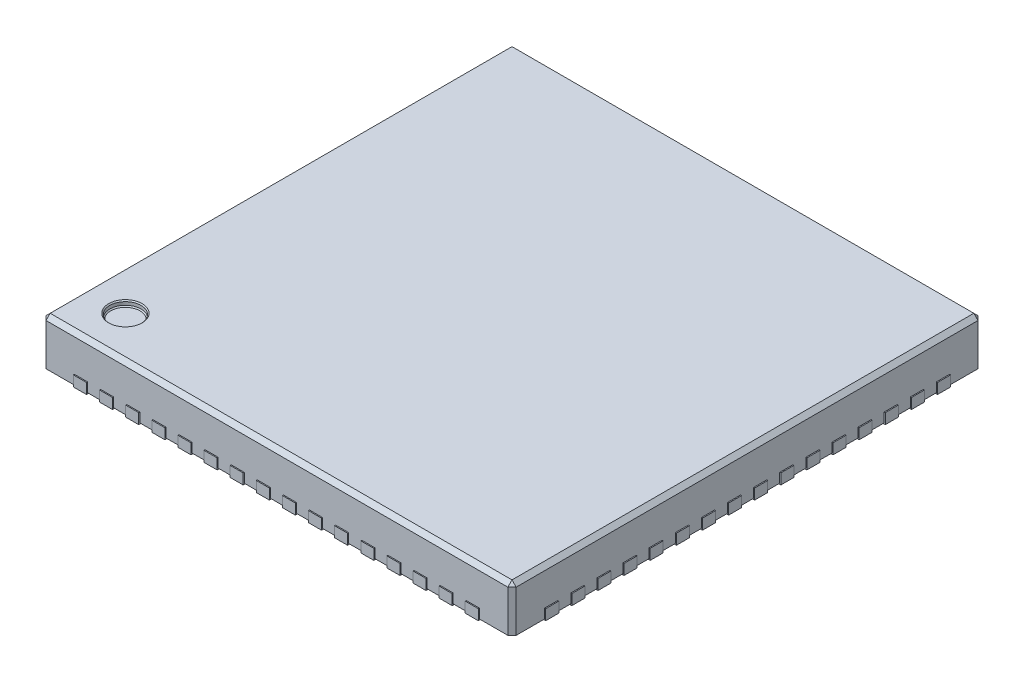
from build123d import *

# Parameters (mm, degrees)
BOSS_EXTRUDE1_DEPTH = 0.88
CHAMFER1_SIZE       = 0.08
SKETCH2_R           = 0.3
CUT_EXTRUDE1_DEPTH  = 0.1
CHAMFER2_SIZE       = 0.02
BOSS_EXTRUDE2_DEPTH = 0.2
LPATTERN1_COUNT     = 8
LPATTERN1_PITCH     = 0.5
LPATTERN2_COUNT     = 9
LPATTERN2_PITCH     = 0.5
CIRPATTERN2_COUNT   = 4
BOSS_EXTRUDE3_DEPTH = 0.2


with BuildPart() as part:
    # 3DSketch1 → Boss-Extrude1 (new body)
    with BuildSketch(Plane(origin=(-4.5, 0.02, 4.5), x_dir=(0.7071067811865474, 0, -0.7071067811865477), z_dir=(0, 1, 0))):
        Polygon((0, 0), (6.363961031, -6.363961031), (12.727922061, 0), (6.363961031, 6.363961031), align=None)
    extrude(amount=BOSS_EXTRUDE1_DEPTH)

    # Chamfer1
    chamfer1_edges = [part.edges().sort_by_distance(p)[0] for p in [
        (-4.5, 0.9, 0),
        (-4.5, 0.46, -4.5),
        (0, 0.9, -4.5),
        (4.5, 0.46, -4.5),
        (4.5, 0.9, 0),
        (-4.5, 0.46, 4.5),
        (0, 0.9, 4.5),
        (4.5, 0.46, 4.5),
    ]]
    chamfer(chamfer1_edges, length=CHAMFER1_SIZE)

    # Sketch2 → Cut-Extrude1 (cut)
    with BuildSketch(Plane(origin=(0, 0.9, 0), x_dir=(1, 0, 0), z_dir=(0, 1, 0))):
        with Locations(Location((-3.7, -3.7, 0), (0, 0, 270))):
            Circle(SKETCH2_R)
    extrude(amount=-CUT_EXTRUDE1_DEPTH, mode=Mode.SUBTRACT)

    # Chamfer2
    chamfer2_edges = [part.edges().sort_by_distance(p)[0] for p in [
        (-3.7, 0.8, 3.4),
        (-3.7, 0.9, 3.4),
    ]]
    chamfer(chamfer2_edges, length=CHAMFER2_SIZE)


with BuildPart() as body_2:
    # Sketch3 → Boss-Extrude2 (new body)
    with BuildSketch(Plane(origin=(0, 0, 0), x_dir=(1, 0, 0), z_dir=(0, 1, 0))):
        with BuildLine():
            Line((0.375, 4.52), (0.125, 4.52))
            Line((0.125, 4.52), (0.125, 4.225))
            ThreePointArc((0.125, 4.225), (0.25, 4.1), (0.375, 4.225))
            Line((0.375, 4.225), (0.375, 4.52))
        make_face()
    extrude(amount=BOSS_EXTRUDE2_DEPTH)


with BuildPart() as lpattern1_1:
    # LPattern1: pattern copy
    add(body_2.part.moved(Location(Vector(1, 0, 0) * (1 * LPATTERN1_PITCH))))


with BuildPart() as lpattern1_2:
    # LPattern1: pattern copy
    add(body_2.part.moved(Location(Vector(1, 0, 0) * (2 * LPATTERN1_PITCH))))


with BuildPart() as lpattern1_3:
    # LPattern1: pattern copy
    add(body_2.part.moved(Location(Vector(1, 0, 0) * (3 * LPATTERN1_PITCH))))


with BuildPart() as lpattern1_4:
    # LPattern1: pattern copy
    add(body_2.part.moved(Location(Vector(1, 0, 0) * (4 * LPATTERN1_PITCH))))


with BuildPart() as lpattern1_5:
    # LPattern1: pattern copy
    add(body_2.part.moved(Location(Vector(1, 0, 0) * (5 * LPATTERN1_PITCH))))


with BuildPart() as lpattern1_6:
    # LPattern1: pattern copy
    add(body_2.part.moved(Location(Vector(1, 0, 0) * (6 * LPATTERN1_PITCH))))


with BuildPart() as lpattern1_7:
    # LPattern1: pattern copy
    add(body_2.part.moved(Location(Vector(1, 0, 0) * (7 * LPATTERN1_PITCH))))


with BuildPart() as lpattern2_1:
    # LPattern2: pattern copy
    add(body_2.part.moved(Location(Vector(-1, 0, 0) * (1 * LPATTERN2_PITCH))))


with BuildPart() as lpattern2_2:
    # LPattern2: pattern copy
    add(body_2.part.moved(Location(Vector(-1, 0, 0) * (2 * LPATTERN2_PITCH))))


with BuildPart() as lpattern2_3:
    # LPattern2: pattern copy
    add(body_2.part.moved(Location(Vector(-1, 0, 0) * (3 * LPATTERN2_PITCH))))


with BuildPart() as lpattern2_4:
    # LPattern2: pattern copy
    add(body_2.part.moved(Location(Vector(-1, 0, 0) * (4 * LPATTERN2_PITCH))))


with BuildPart() as lpattern2_5:
    # LPattern2: pattern copy
    add(body_2.part.moved(Location(Vector(-1, 0, 0) * (5 * LPATTERN2_PITCH))))


with BuildPart() as lpattern2_6:
    # LPattern2: pattern copy
    add(body_2.part.moved(Location(Vector(-1, 0, 0) * (6 * LPATTERN2_PITCH))))


with BuildPart() as lpattern2_7:
    # LPattern2: pattern copy
    add(body_2.part.moved(Location(Vector(-1, 0, 0) * (7 * LPATTERN2_PITCH))))


with BuildPart() as lpattern2_8:
    # LPattern2: pattern copy
    add(body_2.part.moved(Location(Vector(-1, 0, 0) * (8 * LPATTERN2_PITCH))))


with BuildPart() as cirpattern2_1:
    # CirPattern2: pattern copy
    add(lpattern1_7.part.rotate(Axis((0, 0, 0), (0, 1, 0)), 1 * 360 / CIRPATTERN2_COUNT))


with BuildPart() as cirpattern2_2:
    # CirPattern2: pattern copy
    add(lpattern1_7.part.rotate(Axis((0, 0, 0), (0, 1, 0)), 2 * 360 / CIRPATTERN2_COUNT))


with BuildPart() as cirpattern2_3:
    # CirPattern2: pattern copy
    add(lpattern1_7.part.rotate(Axis((0, 0, 0), (0, 1, 0)), 3 * 360 / CIRPATTERN2_COUNT))


with BuildPart() as cirpattern2_4:
    # CirPattern2: pattern copy
    add(lpattern1_6.part.rotate(Axis((0, 0, 0), (0, 1, 0)), 1 * 360 / CIRPATTERN2_COUNT))


with BuildPart() as cirpattern2_5:
    # CirPattern2: pattern copy
    add(lpattern1_6.part.rotate(Axis((0, 0, 0), (0, 1, 0)), 2 * 360 / CIRPATTERN2_COUNT))


with BuildPart() as cirpattern2_6:
    # CirPattern2: pattern copy
    add(lpattern1_6.part.rotate(Axis((0, 0, 0), (0, 1, 0)), 3 * 360 / CIRPATTERN2_COUNT))


with BuildPart() as cirpattern2_7:
    # CirPattern2: pattern copy
    add(lpattern1_5.part.rotate(Axis((0, 0, 0), (0, 1, 0)), 1 * 360 / CIRPATTERN2_COUNT))


with BuildPart() as cirpattern2_8:
    # CirPattern2: pattern copy
    add(lpattern1_5.part.rotate(Axis((0, 0, 0), (0, 1, 0)), 2 * 360 / CIRPATTERN2_COUNT))


with BuildPart() as cirpattern2_9:
    # CirPattern2: pattern copy
    add(lpattern1_5.part.rotate(Axis((0, 0, 0), (0, 1, 0)), 3 * 360 / CIRPATTERN2_COUNT))


with BuildPart() as cirpattern2_10:
    # CirPattern2: pattern copy
    add(lpattern1_4.part.rotate(Axis((0, 0, 0), (0, 1, 0)), 1 * 360 / CIRPATTERN2_COUNT))


with BuildPart() as cirpattern2_11:
    # CirPattern2: pattern copy
    add(lpattern1_4.part.rotate(Axis((0, 0, 0), (0, 1, 0)), 2 * 360 / CIRPATTERN2_COUNT))


with BuildPart() as cirpattern2_12:
    # CirPattern2: pattern copy
    add(lpattern1_4.part.rotate(Axis((0, 0, 0), (0, 1, 0)), 3 * 360 / CIRPATTERN2_COUNT))


with BuildPart() as cirpattern2_13:
    # CirPattern2: pattern copy
    add(lpattern1_3.part.rotate(Axis((0, 0, 0), (0, 1, 0)), 1 * 360 / CIRPATTERN2_COUNT))


with BuildPart() as cirpattern2_14:
    # CirPattern2: pattern copy
    add(lpattern1_3.part.rotate(Axis((0, 0, 0), (0, 1, 0)), 2 * 360 / CIRPATTERN2_COUNT))


with BuildPart() as cirpattern2_15:
    # CirPattern2: pattern copy
    add(lpattern1_3.part.rotate(Axis((0, 0, 0), (0, 1, 0)), 3 * 360 / CIRPATTERN2_COUNT))


with BuildPart() as cirpattern2_16:
    # CirPattern2: pattern copy
    add(lpattern1_2.part.rotate(Axis((0, 0, 0), (0, 1, 0)), 1 * 360 / CIRPATTERN2_COUNT))


with BuildPart() as cirpattern2_17:
    # CirPattern2: pattern copy
    add(lpattern1_2.part.rotate(Axis((0, 0, 0), (0, 1, 0)), 2 * 360 / CIRPATTERN2_COUNT))


with BuildPart() as cirpattern2_18:
    # CirPattern2: pattern copy
    add(lpattern1_2.part.rotate(Axis((0, 0, 0), (0, 1, 0)), 3 * 360 / CIRPATTERN2_COUNT))


with BuildPart() as cirpattern2_19:
    # CirPattern2: pattern copy
    add(lpattern1_1.part.rotate(Axis((0, 0, 0), (0, 1, 0)), 1 * 360 / CIRPATTERN2_COUNT))


with BuildPart() as cirpattern2_20:
    # CirPattern2: pattern copy
    add(lpattern1_1.part.rotate(Axis((0, 0, 0), (0, 1, 0)), 2 * 360 / CIRPATTERN2_COUNT))


with BuildPart() as cirpattern2_21:
    # CirPattern2: pattern copy
    add(lpattern1_1.part.rotate(Axis((0, 0, 0), (0, 1, 0)), 3 * 360 / CIRPATTERN2_COUNT))


with BuildPart() as cirpattern2_22:
    # CirPattern2: pattern copy
    add(body_2.part.rotate(Axis((0, 0, 0), (0, 1, 0)), 1 * 360 / CIRPATTERN2_COUNT))


with BuildPart() as cirpattern2_23:
    # CirPattern2: pattern copy
    add(body_2.part.rotate(Axis((0, 0, 0), (0, 1, 0)), 2 * 360 / CIRPATTERN2_COUNT))


with BuildPart() as cirpattern2_24:
    # CirPattern2: pattern copy
    add(body_2.part.rotate(Axis((0, 0, 0), (0, 1, 0)), 3 * 360 / CIRPATTERN2_COUNT))


with BuildPart() as cirpattern2_25:
    # CirPattern2: pattern copy
    add(lpattern2_1.part.rotate(Axis((0, 0, 0), (0, 1, 0)), 1 * 360 / CIRPATTERN2_COUNT))


with BuildPart() as cirpattern2_26:
    # CirPattern2: pattern copy
    add(lpattern2_1.part.rotate(Axis((0, 0, 0), (0, 1, 0)), 2 * 360 / CIRPATTERN2_COUNT))


with BuildPart() as cirpattern2_27:
    # CirPattern2: pattern copy
    add(lpattern2_1.part.rotate(Axis((0, 0, 0), (0, 1, 0)), 3 * 360 / CIRPATTERN2_COUNT))


with BuildPart() as cirpattern2_28:
    # CirPattern2: pattern copy
    add(lpattern2_2.part.rotate(Axis((0, 0, 0), (0, 1, 0)), 1 * 360 / CIRPATTERN2_COUNT))


with BuildPart() as cirpattern2_29:
    # CirPattern2: pattern copy
    add(lpattern2_2.part.rotate(Axis((0, 0, 0), (0, 1, 0)), 2 * 360 / CIRPATTERN2_COUNT))


with BuildPart() as cirpattern2_30:
    # CirPattern2: pattern copy
    add(lpattern2_2.part.rotate(Axis((0, 0, 0), (0, 1, 0)), 3 * 360 / CIRPATTERN2_COUNT))


with BuildPart() as cirpattern2_31:
    # CirPattern2: pattern copy
    add(lpattern2_3.part.rotate(Axis((0, 0, 0), (0, 1, 0)), 1 * 360 / CIRPATTERN2_COUNT))


with BuildPart() as cirpattern2_32:
    # CirPattern2: pattern copy
    add(lpattern2_3.part.rotate(Axis((0, 0, 0), (0, 1, 0)), 2 * 360 / CIRPATTERN2_COUNT))


with BuildPart() as cirpattern2_33:
    # CirPattern2: pattern copy
    add(lpattern2_3.part.rotate(Axis((0, 0, 0), (0, 1, 0)), 3 * 360 / CIRPATTERN2_COUNT))


with BuildPart() as cirpattern2_34:
    # CirPattern2: pattern copy
    add(lpattern2_4.part.rotate(Axis((0, 0, 0), (0, 1, 0)), 1 * 360 / CIRPATTERN2_COUNT))


with BuildPart() as cirpattern2_35:
    # CirPattern2: pattern copy
    add(lpattern2_4.part.rotate(Axis((0, 0, 0), (0, 1, 0)), 2 * 360 / CIRPATTERN2_COUNT))


with BuildPart() as cirpattern2_36:
    # CirPattern2: pattern copy
    add(lpattern2_4.part.rotate(Axis((0, 0, 0), (0, 1, 0)), 3 * 360 / CIRPATTERN2_COUNT))


with BuildPart() as cirpattern2_37:
    # CirPattern2: pattern copy
    add(lpattern2_5.part.rotate(Axis((0, 0, 0), (0, 1, 0)), 1 * 360 / CIRPATTERN2_COUNT))


with BuildPart() as cirpattern2_38:
    # CirPattern2: pattern copy
    add(lpattern2_5.part.rotate(Axis((0, 0, 0), (0, 1, 0)), 2 * 360 / CIRPATTERN2_COUNT))


with BuildPart() as cirpattern2_39:
    # CirPattern2: pattern copy
    add(lpattern2_5.part.rotate(Axis((0, 0, 0), (0, 1, 0)), 3 * 360 / CIRPATTERN2_COUNT))


with BuildPart() as cirpattern2_40:
    # CirPattern2: pattern copy
    add(lpattern2_6.part.rotate(Axis((0, 0, 0), (0, 1, 0)), 1 * 360 / CIRPATTERN2_COUNT))


with BuildPart() as cirpattern2_41:
    # CirPattern2: pattern copy
    add(lpattern2_6.part.rotate(Axis((0, 0, 0), (0, 1, 0)), 2 * 360 / CIRPATTERN2_COUNT))


with BuildPart() as cirpattern2_42:
    # CirPattern2: pattern copy
    add(lpattern2_6.part.rotate(Axis((0, 0, 0), (0, 1, 0)), 3 * 360 / CIRPATTERN2_COUNT))


with BuildPart() as cirpattern2_43:
    # CirPattern2: pattern copy
    add(lpattern2_7.part.rotate(Axis((0, 0, 0), (0, 1, 0)), 1 * 360 / CIRPATTERN2_COUNT))


with BuildPart() as cirpattern2_44:
    # CirPattern2: pattern copy
    add(lpattern2_7.part.rotate(Axis((0, 0, 0), (0, 1, 0)), 2 * 360 / CIRPATTERN2_COUNT))


with BuildPart() as cirpattern2_45:
    # CirPattern2: pattern copy
    add(lpattern2_7.part.rotate(Axis((0, 0, 0), (0, 1, 0)), 3 * 360 / CIRPATTERN2_COUNT))


with BuildPart() as cirpattern2_46:
    # CirPattern2: pattern copy
    add(lpattern2_8.part.rotate(Axis((0, 0, 0), (0, 1, 0)), 1 * 360 / CIRPATTERN2_COUNT))


with BuildPart() as cirpattern2_47:
    # CirPattern2: pattern copy
    add(lpattern2_8.part.rotate(Axis((0, 0, 0), (0, 1, 0)), 2 * 360 / CIRPATTERN2_COUNT))


with BuildPart() as cirpattern2_48:
    # CirPattern2: pattern copy
    add(lpattern2_8.part.rotate(Axis((0, 0, 0), (0, 1, 0)), 3 * 360 / CIRPATTERN2_COUNT))


with BuildPart() as body_66:
    # Sketch4 → Boss-Extrude3 (new body)
    with BuildSketch(Plane(origin=(0, 0, 0), x_dir=(1, 0, 0), z_dir=(0, 1, 0))):
        with BuildLine():
            Line((-3.178047264, -3.55), (3.45, -3.55))
            ThreePointArc((3.45, -3.55), (3.520710678, -3.520710678), (3.55, -3.45))
            Line((3.55, -3.45), (3.55, 3.45))
            ThreePointArc((3.55, 3.45), (3.520710678, 3.520710678), (3.45, 3.55))
            Line((3.45, 3.55), (-3.45, 3.55))
            ThreePointArc((-3.45, 3.55), (-3.520710678, 3.520710678), (-3.55, 3.45))
            Line((-3.55, 3.45), (-3.55, -3.178047264))
            ThreePointArc((-3.55, -3.178047264), (-3.544516836, -3.191804497), (-3.531073854, -3.198018414))
            ThreePointArc((-3.531073854, -3.198018414), (-3.300751895, -3.300751895), (-3.198018414, -3.531073854))
            ThreePointArc((-3.198018414, -3.531073854), (-3.191804497, -3.544516836), (-3.178047264, -3.55))
        make_face()
    extrude(amount=BOSS_EXTRUDE3_DEPTH)


solid = Compound([part.part, body_2.part, lpattern1_1.part, lpattern1_2.part, lpattern1_3.part, lpattern1_4.part, lpattern1_5.part, lpattern1_6.part, lpattern1_7.part, lpattern2_1.part, lpattern2_2.part, lpattern2_3.part, lpattern2_4.part, lpattern2_5.part, lpattern2_6.part, lpattern2_7.part, lpattern2_8.part, cirpattern2_1.part, cirpattern2_2.part, cirpattern2_3.part, cirpattern2_4.part, cirpattern2_5.part, cirpattern2_6.part, cirpattern2_7.part, cirpattern2_8.part, cirpattern2_9.part, cirpattern2_10.part, cirpattern2_11.part, cirpattern2_12.part, cirpattern2_13.part, cirpattern2_14.part, cirpattern2_15.part, cirpattern2_16.part, cirpattern2_17.part, cirpattern2_18.part, cirpattern2_19.part, cirpattern2_20.part, cirpattern2_21.part, cirpattern2_22.part, cirpattern2_23.part, cirpattern2_24.part, cirpattern2_25.part, cirpattern2_26.part, cirpattern2_27.part, cirpattern2_28.part, cirpattern2_29.part, cirpattern2_30.part, cirpattern2_31.part, cirpattern2_32.part, cirpattern2_33.part, cirpattern2_34.part, cirpattern2_35.part, cirpattern2_36.part, cirpattern2_37.part, cirpattern2_38.part, cirpattern2_39.part, cirpattern2_40.part, cirpattern2_41.part, cirpattern2_42.part, cirpattern2_43.part, cirpattern2_44.part, cirpattern2_45.part, cirpattern2_46.part, cirpattern2_47.part, cirpattern2_48.part, body_66.part])
